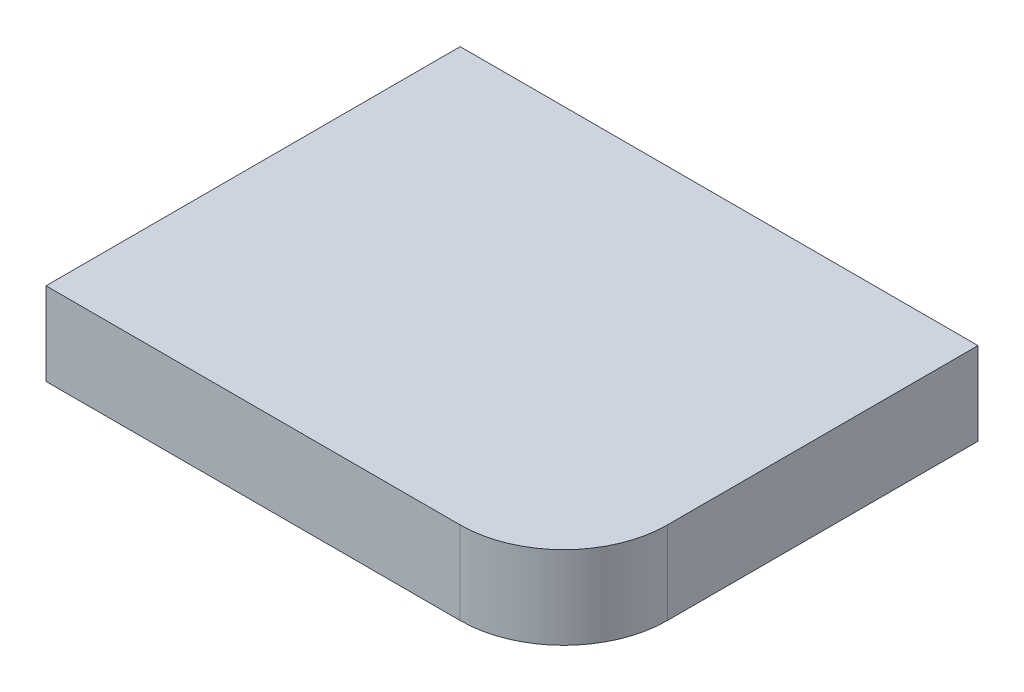
from build123d import *

# Parameters (mm, degrees)
EXTRUDE_1_DEPTH = 8


with BuildPart() as part:
    # Эскиз1 → Бобышка-Вытянуть1 (new body)
    with BuildSketch(Plane(origin=(0, 0, 0), x_dir=(1, 0, 0), z_dir=(0, 1, 0))):
        with BuildLine():
            Line((-25, -20), (15, -20))
            ThreePointArc((15, -20), (22.071067812, -17.071067812), (25, -10))
            Line((25, -10), (25, 20))
            Line((25, 20), (-25, 20))
            Line((-25, 20), (-25, -20))
        make_face()
    extrude(amount=EXTRUDE_1_DEPTH)


solid = part.part
